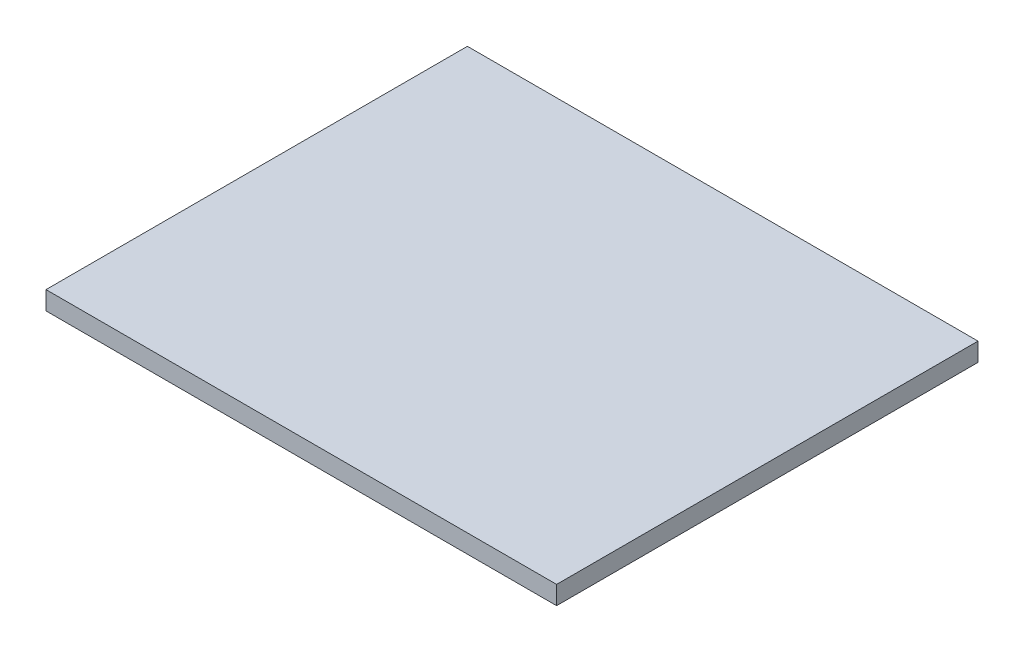
from build123d import *

# Parameters (mm, degrees)
SKETCH1_W           = 83
SKETCH1_H           = 3
BOSS_EXTRUDE1_DEPTH = 68.5


with BuildPart() as part:
    # Sketch1 → Boss-Extrude1 (new body)
    with BuildSketch(Plane.XY):
        with Locations((83.3, -221.5)):
            Rectangle(SKETCH1_W, SKETCH1_H)
    extrude(amount=BOSS_EXTRUDE1_DEPTH)


solid = part.part
